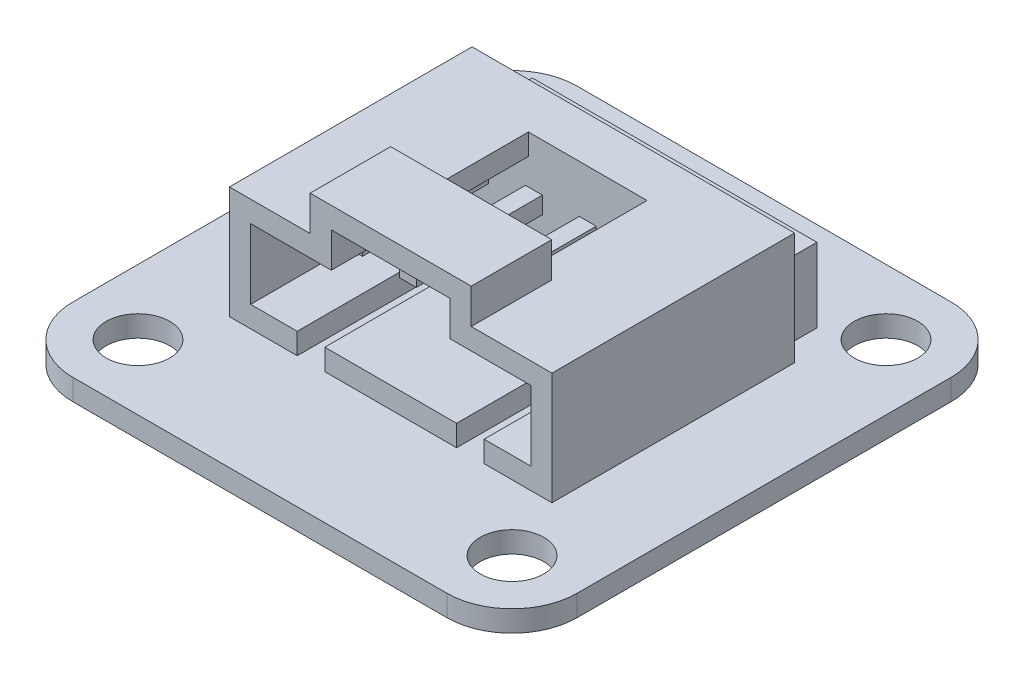
from build123d import *

# Parameters (mm, degrees)
SKETCH1_R           = 1.5
BOSS_EXTRUDE1_DEPTH = 1
SKETCH2_W           = 15.22
SKETCH2_H           = 11.45
BOSS_EXTRUDE2_DEPTH = 5.3
SKETCH3_W           = 13.43
SKETCH3_H           = 1.95
BOSS_EXTRUDE3_DEPTH = 3.5
SKETCH5_W           = 7.6
SKETCH5_H           = 3.8
BOSS_EXTRUDE4_DEPTH = 1.65
SKETCH4_W           = 13.22
SKETCH4_H           = 3.3
SKETCH4_W_2         = 5.6
SKETCH4_H_2         = 1.65
SKETCH4_W_3         = 1.3
SKETCH4_H_3         = 1
CUT_EXTRUDE1_DEPTH  = 9.3
SKETCH6_W           = 0.8
SKETCH6_H           = 0.8
BOSS_EXTRUDE5_DEPTH = 5.95
SKETCH7_W           = 4
SKETCH7_H           = 5.1
BOSS_EXTRUDE6_DEPTH = 1.6
FILLET1_R           = 0.25


with BuildPart() as part:
    # Sketch1 → Boss-Extrude1 (new body)
    with BuildSketch(Plane(origin=(0, 0, 0), x_dir=(1, 0, 0), z_dir=(0, 1, 0))):
        with BuildLine():
            ThreePointArc((-11.9, -8.825), (-10.999353352, -10.999353352), (-8.825, -11.9))
            Line((-8.825, -11.9), (8.825, -11.9))
            ThreePointArc((8.825, -11.9), (10.999353352, -10.999353352), (11.9, -8.825))
            Line((11.9, -8.825), (11.9, 8.825))
            ThreePointArc((11.9, 8.825), (10.999353357, 10.999353347), (8.825000015, 11.9))
            Line((8.825000015, 11.9), (-8.825, 11.9))
            ThreePointArc((-8.825, 11.9), (-10.999353347, 10.999353357), (-11.9, 8.825000015))
            Line((-11.9, 8.825000015), (-11.9, -8.825))
        make_face()
        with Locations((8.825, -8.825)):
            Circle(SKETCH1_R, mode=Mode.SUBTRACT)
        with Locations((-8.825, -8.825)):
            Circle(SKETCH1_R, mode=Mode.SUBTRACT)
        with Locations((-8.825, 8.825)):
            Circle(SKETCH1_R, mode=Mode.SUBTRACT)
        with Locations((8.825, 8.825)):
            Circle(SKETCH1_R, mode=Mode.SUBTRACT)
    extrude(amount=BOSS_EXTRUDE1_DEPTH)

    # Sketch2 → Boss-Extrude2 (add)
    with BuildSketch(Plane(origin=(0, 1, 0), x_dir=(1, 0, 0), z_dir=(0, 1, 0))):
        Rectangle(SKETCH2_W, SKETCH2_H)
    extrude(amount=BOSS_EXTRUDE2_DEPTH)

    # Sketch3 → Boss-Extrude3 (add)
    with BuildSketch(Plane(origin=(0, 1, 0), x_dir=(1, 0, 0), z_dir=(0, 1, 0))):
        with Locations((0, 6.7)):
            Rectangle(SKETCH3_W, SKETCH3_H)
    extrude(amount=BOSS_EXTRUDE3_DEPTH)

    # Sketch5 → Boss-Extrude4 (add)
    with BuildSketch(Plane(origin=(0, 6.3, 0), x_dir=(1, 0, 0), z_dir=(0, 1, 0))):
        with Locations((0, -3.825)):
            Rectangle(SKETCH5_W, SKETCH5_H)
    extrude(amount=BOSS_EXTRUDE4_DEPTH)

    # Sketch4 → Cut-Extrude1 (cut)
    with BuildSketch(Plane.XY.offset(5.725)):
        with Locations((0, 3.65)):
            Rectangle(SKETCH4_W, SKETCH4_H)
        with Locations((0, 6.125)):
            Rectangle(SKETCH4_W_2, SKETCH4_H_2)
        with Locations((-3.76, 1.5)):
            Rectangle(SKETCH4_W_3, SKETCH4_H_3)
        with Locations((3.76, 1.5)):
            Rectangle(SKETCH4_W_3, SKETCH4_H_3)
    extrude(amount=-CUT_EXTRUDE1_DEPTH, mode=Mode.SUBTRACT)

    # Sketch6 → Boss-Extrude5 (add)
    with BuildSketch(Plane.XY.offset(-3.575)):
        with Locations((2.54, 3.65)):
            Rectangle(SKETCH6_W, SKETCH6_H)
        with Locations((0, 3.65)):
            Rectangle(SKETCH6_W, SKETCH6_H)
        with Locations((5.08, 3.65)):
            Rectangle(SKETCH6_W, SKETCH6_H)
        with Locations((-2.54, 3.65)):
            Rectangle(SKETCH6_W, SKETCH6_H)
        with Locations((-5.08, 3.65)):
            Rectangle(SKETCH6_W, SKETCH6_H)
    extrude(amount=BOSS_EXTRUDE5_DEPTH)

    # Sketch7 → Boss-Extrude6 (add)
    with BuildSketch(Plane.XZ):
        Rectangle(SKETCH7_W, SKETCH7_H)
    extrude(amount=BOSS_EXTRUDE6_DEPTH)

    # Fillet1
    fillet1_edges = [part.edges().sort_by_distance(p)[0] for p in [
        (2, -1.6, 0),
        (0, -1.6, 2.55),
        (-2, -1.6, 0),
        (0, -1.6, -2.55),
    ]]
    fillet(fillet1_edges, radius=FILLET1_R)


solid = part.part
